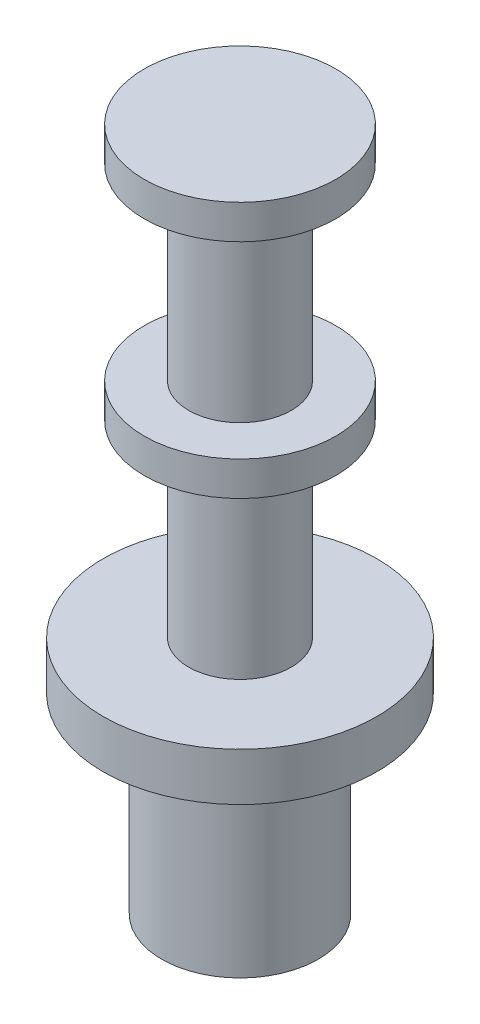
from build123d import *

# Parameters (mm, degrees)
SKETCH1_R           = 2
BOSS_EXTRUDE1_DEPTH = 0.7
SKETCH2_R           = 0.75
BOSS_EXTRUDE2_DEPTH = 2.75
SKETCH3_R           = 1.4
BOSS_EXTRUDE3_DEPTH = 0.5
SKETCH4_R           = 0.75
BOSS_EXTRUDE4_DEPTH = 2.75
SKETCH5_R           = 1.4
BOSS_EXTRUDE5_DEPTH = 0.5
SKETCH6_R           = 1.145
BOSS_EXTRUDE6_DEPTH = 2.8


with BuildPart() as part:
    # Sketch1 → Boss-Extrude1 (new body)
    with BuildSketch(Plane(origin=(0, 0, 0), x_dir=(1, 0, 0), z_dir=(0, 1, 0))):
        Circle(SKETCH1_R)
    extrude(amount=BOSS_EXTRUDE1_DEPTH)

    # Sketch2 → Boss-Extrude2 (add)
    with BuildSketch(Plane(origin=(0, 0.7, 0), x_dir=(1, 0, 0), z_dir=(0, 1, 0))):
        Circle(SKETCH2_R)
    extrude(amount=BOSS_EXTRUDE2_DEPTH)

    # Sketch3 → Boss-Extrude3 (add)
    with BuildSketch(Plane(origin=(0, 3.45, 0), x_dir=(1, 0, 0), z_dir=(0, 1, 0))):
        Circle(SKETCH3_R)
    extrude(amount=BOSS_EXTRUDE3_DEPTH)

    # Sketch4 → Boss-Extrude4 (add)
    with BuildSketch(Plane(origin=(0, 3.95, 0), x_dir=(1, 0, 0), z_dir=(0, 1, 0))):
        Circle(SKETCH4_R)
    extrude(amount=BOSS_EXTRUDE4_DEPTH)

    # Sketch5 → Boss-Extrude5 (add)
    with BuildSketch(Plane(origin=(0, 6.7, 0), x_dir=(1, 0, 0), z_dir=(0, 1, 0))):
        Circle(SKETCH5_R)
    extrude(amount=BOSS_EXTRUDE5_DEPTH)

    # Sketch6 → Boss-Extrude6 (add)
    with BuildSketch(Plane.XZ):
        Circle(SKETCH6_R)
    extrude(amount=BOSS_EXTRUDE6_DEPTH)


solid = part.part
